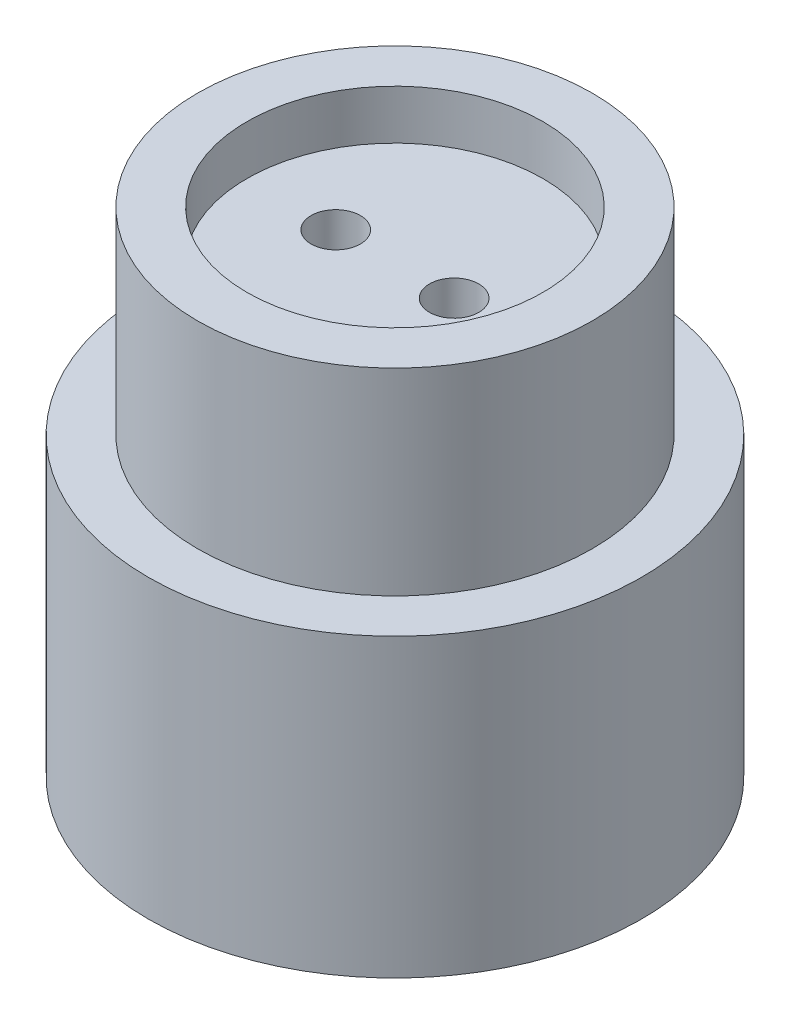
from build123d import *

# Parameters (mm, degrees)
SKETCH2_R           = 25
SKETCH2_R_2         = 20
BOSS_EXTRUDE1_DEPTH = 30
SKETCH2_4_R         = 20
BOSS_EXTRUDE2_DEPTH = 50
SKETCH3_4_W         = 2.5
SKETCH3_4_H         = 25.5
SKETCH3_5_W         = 15
SKETCH3_5_H         = 5
SKETCH4_R           = 2.5


with BuildPart() as part:
    # Sketch2 → Boss-Extrude1 (new body)
    with BuildSketch(Plane(origin=(0, 0, 0), x_dir=(1, 0, 0), z_dir=(0, 1, 0))):
        Circle(SKETCH2_R)
        Circle(SKETCH2_R_2, mode=Mode.SUBTRACT)
    extrude(amount=BOSS_EXTRUDE1_DEPTH)


with BuildPart() as body_2:
    # Sketch2_4 → Boss-Extrude2 (new body)
    with BuildSketch(Plane(origin=(0, 0, 0), x_dir=(1, 0, 0), z_dir=(0, 1, 0))):
        Circle(SKETCH2_4_R)
    extrude(amount=BOSS_EXTRUDE2_DEPTH)

    # Sketch3 → Cut-Revolve1 (revolve, cut)
    with BuildSketch(Plane.XY):
        Polygon((-15, 42), (-9.5, 42), (-9.5, 23.5), (-16.5, 23.5), (-16.5, 5), (-20, 5), (-20, 25), (-15, 25), align=None)
    revolve(axis=Axis((0, 50, 0), (0, -1, 0)), mode=Mode.SUBTRACT)

    # Sketch3_4 → Cut-Revolve2 (revolve, cut)
    with BuildSketch(Plane.XY):
        with Locations((-1.25, 29.25)):
            Rectangle(SKETCH3_4_W, SKETCH3_4_H)
        Polygon((0, 16.5), (-2.5, 16.5), (-9.5, 16.5), (-9.5, 5), (0, 5), align=None)
    revolve(axis=Axis((0, 50, 0), (0, -1, 0)), mode=Mode.SUBTRACT)

    # Sketch3_5 → Cut-Revolve3 (revolve, cut)
    with BuildSketch(Plane.XY):
        with Locations((-7.5, 47.5)):
            Rectangle(SKETCH3_5_W, SKETCH3_5_H)
    revolve(axis=Axis((0, 50, 0), (0, -1, 0)), mode=Mode.SUBTRACT)

    # Cut-Sweep1: sweep along a path in Sketch3_10
    with BuildLine(Plane.XY) as cut_sweep1_path:
        Line((-6, 45), (-6, 20))
        Line((-6, 20), (-13, 20))
        Line((-13, 20), (-13, 0))
    # Sketch4 → Cut-Sweep1 (sweep, cut)
    with BuildSketch(Plane(origin=(0, 45, 0), x_dir=(1, 0, 0), z_dir=(0, 1, 0))):
        with Locations((-6, 0)):
            Circle(SKETCH4_R)
    cut_sweep1 = sweep(path=cut_sweep1_path.line, transition=Transition.RIGHT, mode=Mode.SUBTRACT)

    # Mirror1: Cut-Sweep1 across plane
    add(cut_sweep1.mirror(Plane(origin=(0, 0, 0), x_dir=(0, 0, 1), z_dir=(1, 0, 0))), mode=Mode.SUBTRACT)


solid = Compound([part.part, body_2.part])
